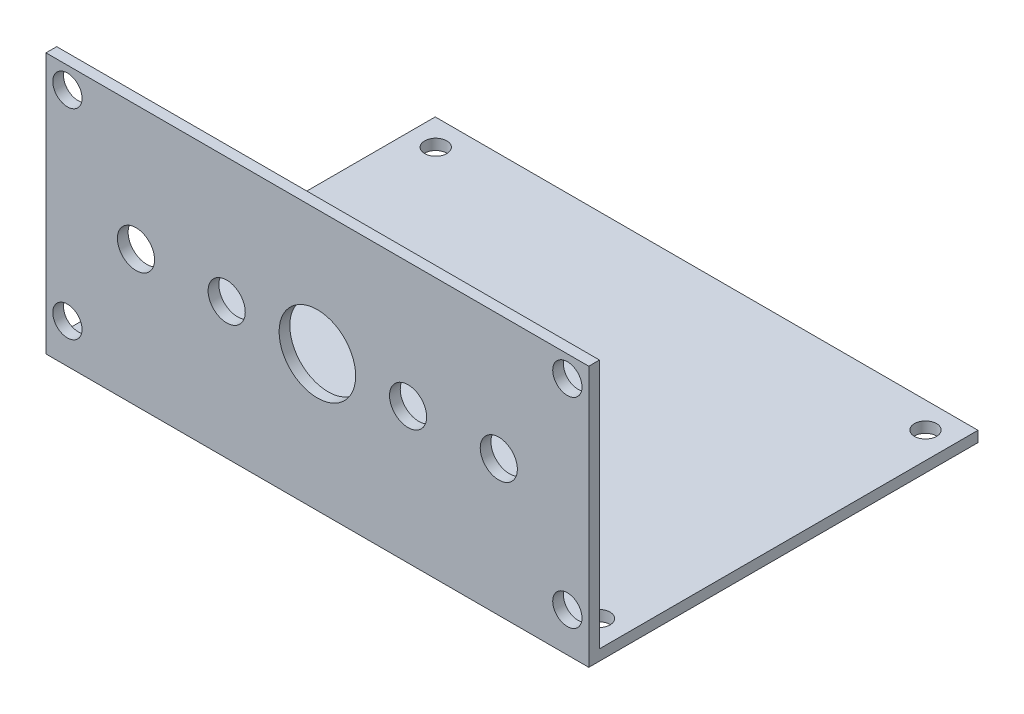
from build123d import *

# Parameters (mm, degrees)
SKETCH_1_W          = 76
SKETCH_1_H          = 53
SKETCH_1_R          = 1.55
EXTRUDE_1_DEPTH     = 1.5
SKETCH_2_W          = 76
SKETCH_2_H          = 1.5
EXTRUDE_2_DEPTH     = 1.5
SKETCH_3_W          = 76
SKETCH_3_H          = 1.5
EXTRUDE_3_DEPTH     = 35.02
SKETCH_4_R          = 5.36
SKETCH_4_R_2        = 2.600000007
CUT_EXTRUDE_1_DEPTH = 60
SKETCH_5_R          = 2.05
CUT_EXTRUDE_2_DEPTH = 10


with BuildPart() as part:
    # 草图1 → 凸台-拉伸1 (new body)
    with BuildSketch(Plane(origin=(0, 0, 0), x_dir=(1, 0, 0), z_dir=(0, 1, 0))):
        Rectangle(SKETCH_1_W, SKETCH_1_H)
        with Locations((-34.29, 22.86)):
            Circle(SKETCH_1_R, mode=Mode.SUBTRACT)
        with Locations((-34.29, -22.86)):
            Circle(SKETCH_1_R, mode=Mode.SUBTRACT)
        with Locations((34.29, -22.86)):
            Circle(SKETCH_1_R, mode=Mode.SUBTRACT)
        with Locations((34.29, 22.86)):
            Circle(SKETCH_1_R, mode=Mode.SUBTRACT)
    extrude(amount=EXTRUDE_1_DEPTH)

    # 草图2 → 凸台-拉伸2 (add)
    with BuildSketch(Plane.XY.offset(26.5)):
        with Locations((0, 0.75)):
            Rectangle(SKETCH_2_W, SKETCH_2_H)
    extrude(amount=EXTRUDE_2_DEPTH)

    # 草图3 → 凸台-拉伸3 (add)
    with BuildSketch(Plane(origin=(0, 1.5, 0), x_dir=(1, 0, 0), z_dir=(0, 1, 0))):
        with Locations((0, -27.25)):
            Rectangle(SKETCH_3_W, SKETCH_3_H)
    extrude(amount=EXTRUDE_3_DEPTH)

    # 草图4 → 切除-拉伸1 (cut)
    with BuildSketch(Plane(origin=(0, 0, 26.5), x_dir=(-1, 0, 0), z_dir=(0, 0, -1))):
        with Locations((0, 19.02)):
            Circle(SKETCH_4_R)
        with Locations((-12.7, 19.02)):
            Circle(SKETCH_4_R_2)
        with Locations((-25.4, 19.02)):
            Circle(SKETCH_4_R_2)
        with Locations((12.7, 19.02)):
            Circle(SKETCH_4_R_2)
        with Locations((25.4, 19.02)):
            Circle(SKETCH_4_R_2)
    extrude(amount=-CUT_EXTRUDE_1_DEPTH, mode=Mode.SUBTRACT)

    # 草图5 → 切除-拉伸2 (cut)
    with BuildSketch(Plane(origin=(0, 0, 26.5), x_dir=(-1, 0, 0), z_dir=(0, 0, -1))):
        with Locations((-35, 33.52)):
            Circle(SKETCH_5_R)
        with Locations((-35, 5.5)):
            Circle(SKETCH_5_R)
        with Locations((35, 5.5)):
            Circle(SKETCH_5_R)
        with Locations((35, 33.52)):
            Circle(SKETCH_5_R)
    extrude(amount=-CUT_EXTRUDE_2_DEPTH, mode=Mode.SUBTRACT)


solid = part.part
